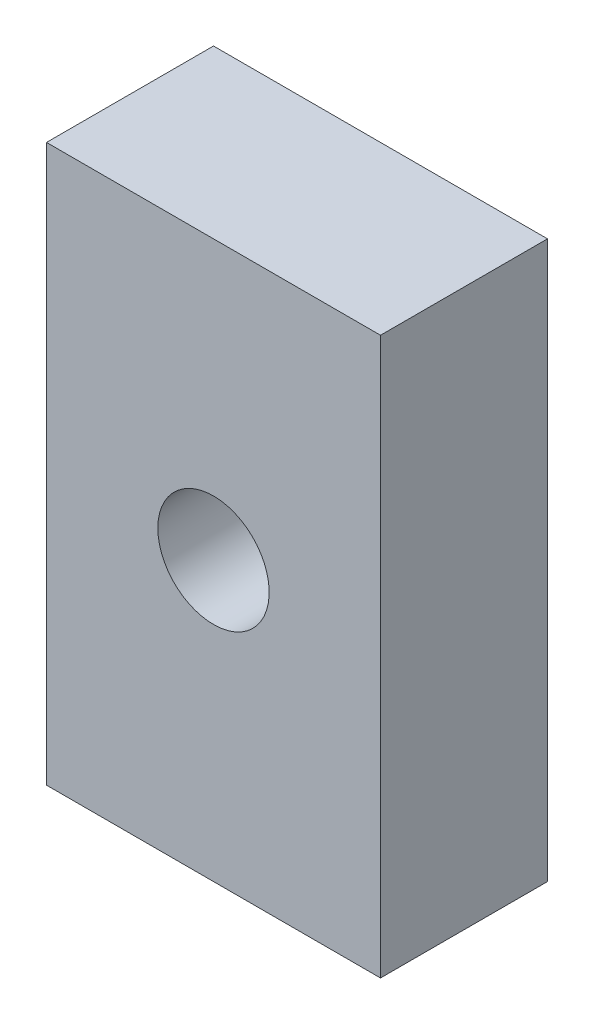
from build123d import *

# Parameters (mm, degrees)
SKETCH1_W                  = 38.1
SKETCH1_H                  = 63.5
EXTRUDE1_DEPTH             = 19.05
F_1_2_0_5_DIAMETER_HOLE1_D = 12.7


with BuildPart() as part:
    # Sketch1 → Extrude1 (new body)
    with BuildSketch(Plane.XY):
        Rectangle(SKETCH1_W, SKETCH1_H)
    extrude(amount=EXTRUDE1_DEPTH)

    # 1/2 (0.5) Diameter Hole1 (through all)
    with Locations(Plane(origin=(0, 0, 0), x_dir=(-1, 0, 0), z_dir=(0, 0, -1))):
        with Locations((0, 0)):
            Hole(F_1_2_0_5_DIAMETER_HOLE1_D / 2)


solid = part.part
